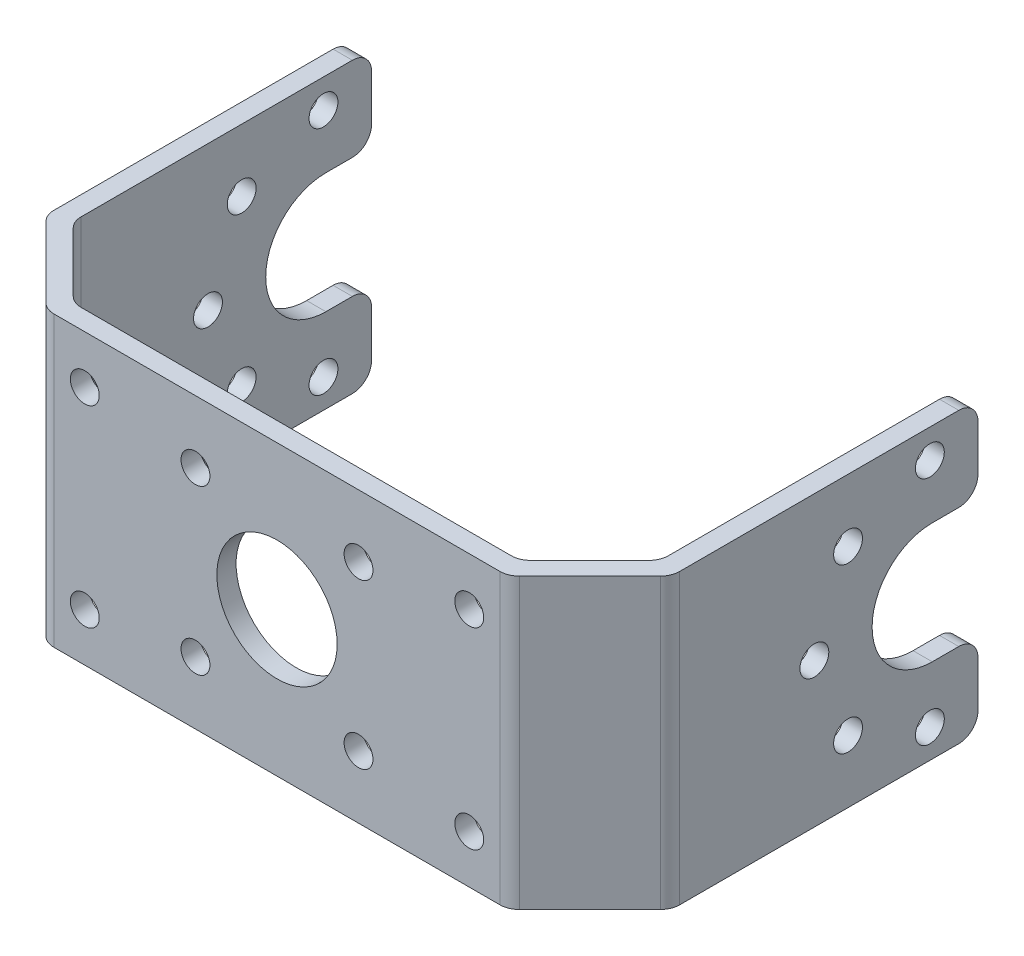
from build123d import *

# Parameters (mm, degrees)
BOSS_EXTRUDE2_DEPTH = 30
SKETCH2_R           = 1.5
CUT_EXTRUDE1_DEPTH  = 66
SKETCH3_R           = 6.25
SKETCH3_R_2         = 1.5
CUT_EXTRUDE2_DEPTH  = 10
FILLET1_R           = 2


with BuildPart() as part:
    # Sketch1 → Boss-Extrude2 (new body)
    with BuildSketch(Plane(origin=(0, 0, 0), x_dir=(1, 0, 0), z_dir=(0, 1, 0))):
        Polygon((0, -38.328427125), (23.171572875, -38.328427125), (30.5, -31), (30.5, 0), (32.5, 0), (32.5, -31.828427125), (24, -40.328427125), (0, -40.328427125), align=None)
    boss_extrude2 = extrude(amount=BOSS_EXTRUDE2_DEPTH)

    # Mirror1: Boss-Extrude2 across plane
    add(boss_extrude2.mirror(Plane(origin=(0, 0, 0), x_dir=(0, 0, 1), z_dir=(1, 0, 0))))

    # Sketch2 → Cut-Extrude1 (cut, through all)
    with BuildSketch(Plane(origin=(32.5, 0, 0), x_dir=(0, 0, -1), z_dir=(1, 0, 0))):
        with Locations((-17, 15)):
            Circle(SKETCH2_R)
        with Locations((-5, 3)):
            Circle(SKETCH2_R)
        with Locations((-13.5, 6.5)):
            Circle(SKETCH2_R)
        with Locations((-13.5, 23.5)):
            Circle(SKETCH2_R)
        with Locations((-5, 27)):
            Circle(SKETCH2_R)
        with BuildLine():
            Line((-4.75, 21.25), (0, 21.25))
            Line((0, 21.25), (0, 8.75))
            Line((0, 8.75), (-4.75, 8.75))
            ThreePointArc((-4.75, 8.75), (-11, 15), (-4.75, 21.25))
        make_face()
    extrude(amount=-CUT_EXTRUDE1_DEPTH, mode=Mode.SUBTRACT)

    # Sketch3 → Cut-Extrude2 (cut)
    with BuildSketch(Plane.XY.offset(40.328427125)):
        with Locations((0, 15)):
            Circle(SKETCH3_R)
        with Locations((8.470537173, 6.5)):
            Circle(SKETCH3_R_2)
        with Locations((8.470537173, 23.5)):
            Circle(SKETCH3_R_2)
        with Locations((19.970537173, 5)):
            Circle(SKETCH3_R_2)
        with Locations((19.970537173, 25)):
            Circle(SKETCH3_R_2)
        with Locations((-19.970537173, 5)):
            Circle(SKETCH3_R_2)
        with Locations((-8.470537173, 6.5)):
            Circle(SKETCH3_R_2)
        with Locations((-19.970537173, 25)):
            Circle(SKETCH3_R_2)
        with Locations((-8.470537173, 23.5)):
            Circle(SKETCH3_R_2)
    extrude(amount=-CUT_EXTRUDE2_DEPTH, mode=Mode.SUBTRACT)

    # Fillet1
    fillet1_edges = [part.edges().sort_by_distance(p)[0] for p in [
        (31.5, 0, 0),
        (32.5, 15, 31.828427125),
        (24, 15, 40.328427125),
        (23.171572875, 15, 38.328427125),
        (30.5, 15, 31),
        (-31.5, 30, 0),
        (-32.5, 15, 31.828427125),
        (-24, 15, 40.328427125),
        (-23.171572875, 15, 38.328427125),
        (-30.5, 15, 31),
        (-31.5, 0, 0),
        (31.5, 30, 0),
        (31.5, 21.25, 0),
        (31.5, 8.75, 0),
        (-31.5, 21.25, 0),
        (-31.5, 8.75, 0),
    ]]
    fillet(fillet1_edges, radius=FILLET1_R)


solid = part.part
